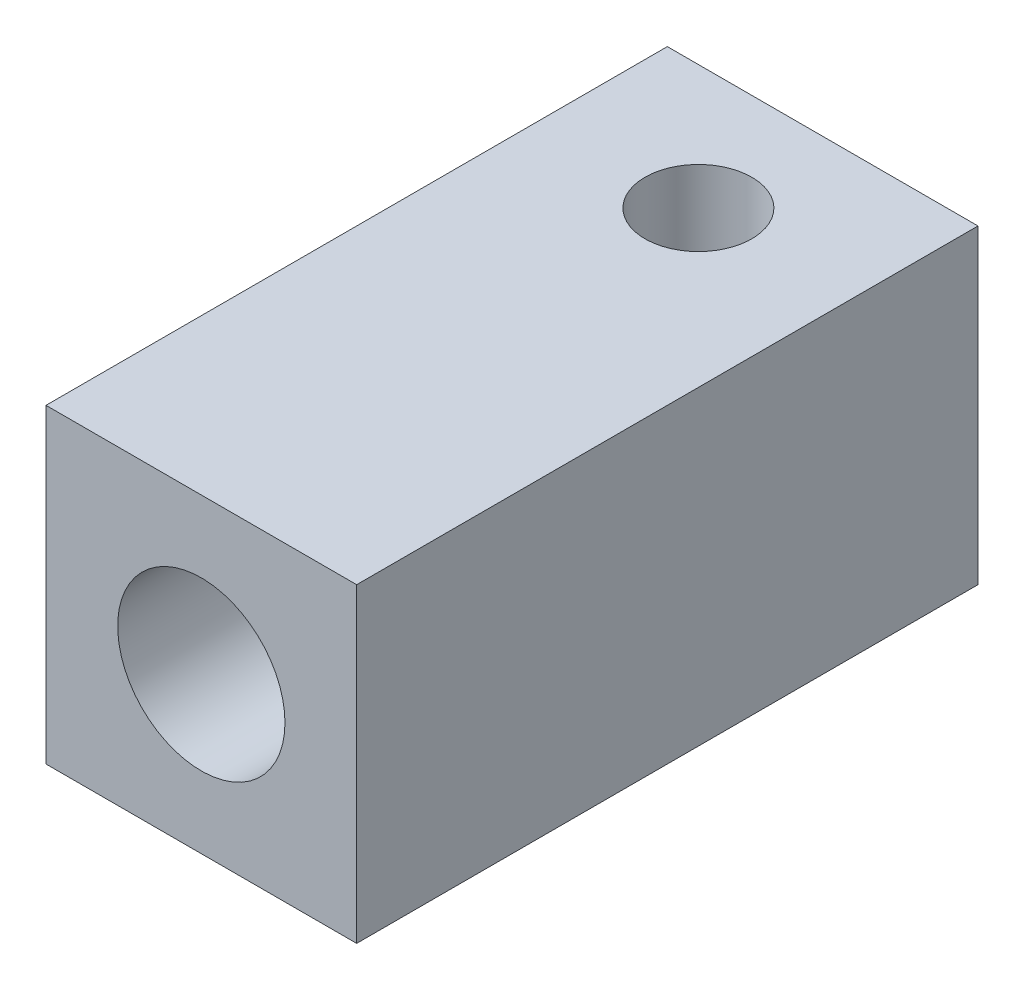
from build123d import *

# Parameters (mm, degrees)
SKETCH1_W                     = 7.5
SKETCH1_H                     = 7.5
BOSS_EXTRUDE1_DEPTH           = 15
HOLE_FOR_TUBING_R             = 1.1
CUT_EXTRUDE1_DEPTH            = 16
F_10_32_HOLE_FOR_LUER_SCREW_R = 2.0193
CUT_EXTRUDE2_DEPTH            = 7.5
F_5_40_SET_SCREW_HOLE_R       = 1.28905
CUT_EXTRUDE3_DEPTH            = 2


with BuildPart() as part:
    # Sketch1 → Boss-Extrude1 (new body)
    with BuildSketch(Plane.XY):
        with Locations((-4.663043478, 0.989130435)):
            Rectangle(SKETCH1_W, SKETCH1_H)
    extrude(amount=BOSS_EXTRUDE1_DEPTH)

    # hole for tubing → Cut-Extrude1 (cut, through all)
    with BuildSketch(Plane(origin=(0, 0, 0), x_dir=(-1, 0, 0), z_dir=(0, 0, -1))):
        with Locations((4.663043478, 0.989130435)):
            Circle(HOLE_FOR_TUBING_R)
    extrude(amount=-CUT_EXTRUDE1_DEPTH, mode=Mode.SUBTRACT)

    # 10-32 hole for luer screw → Cut-Extrude2 (cut)
    with BuildSketch(Plane.XY.offset(15)):
        with Locations((-4.663043478, 0.989130435)):
            Circle(F_10_32_HOLE_FOR_LUER_SCREW_R)
    extrude(amount=-CUT_EXTRUDE2_DEPTH, mode=Mode.SUBTRACT)

    # 5-40 set screw hole → Cut-Extrude3 (cut)
    with BuildSketch(Plane(origin=(0, 4.739130435, 0), x_dir=(1, 0, 0), z_dir=(0, 1, 0))):
        with Locations((-4.663043478, -3)):
            Circle(F_5_40_SET_SCREW_HOLE_R)
    extrude(amount=-CUT_EXTRUDE3_DEPTH, mode=Mode.SUBTRACT)


solid = part.part
